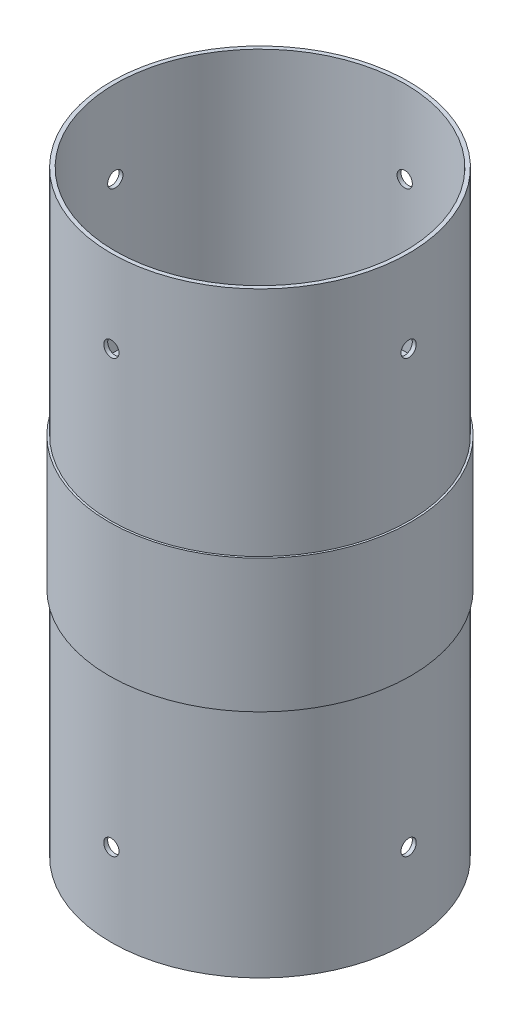
from build123d import *

# Parameters (mm, degrees)
SKETCH1_R                = 38
SKETCH1_R_2              = 37
BOSS_EXTRUDE1_DEPTH      = 152.4
SKETCH2_R                = 38.5
BOSS_EXTRUDE2_DEPTH      = 17
BOSS_EXTRUDE2_DEPTH_BACK = 17
SKETCH3_R                = 1.95
CUT_EXTRUDE1_DEPTH       = 39.5
SKETCH4_R                = 1.95
CUT_EXTRUDE2_DEPTH       = 39.5


with BuildPart() as part:
    # Sketch1 → Boss-Extrude1 (new body)
    with BuildSketch(Plane(origin=(0, 0, 0), x_dir=(1, 0, 0), z_dir=(0, 1, 0))):
        Circle(SKETCH1_R)
        Circle(SKETCH1_R_2, mode=Mode.SUBTRACT)
    extrude(amount=BOSS_EXTRUDE1_DEPTH)

    # Sketch2 → Boss-Extrude2 (add, two sides)
    with BuildSketch(Plane(origin=(0, 76.2, 0), x_dir=(1, 0, 0), z_dir=(0, 1, 0))) as boss_extrude2_sk:
        Circle(SKETCH2_R)
    extrude(amount=BOSS_EXTRUDE2_DEPTH)
    extrude(boss_extrude2_sk.sketch, amount=-BOSS_EXTRUDE2_DEPTH_BACK)

    # Sketch3 → Cut-Extrude1 (cut, symmetric)
    with BuildSketch(Plane(origin=(0, 0, 0), x_dir=(0, 0, -1), z_dir=(1, 0, 0))):
        with Locations((0, 131.3)):
            Circle(SKETCH3_R)
    cut_extrude1 = extrude(amount=CUT_EXTRUDE1_DEPTH, both=True, mode=Mode.SUBTRACT)

    # Sketch4 → Cut-Extrude2 (cut, symmetric)
    with BuildSketch(Plane.XY):
        with Locations((0, 131.3)):
            Circle(SKETCH4_R)
    cut_extrude2 = extrude(amount=CUT_EXTRUDE2_DEPTH, both=True, mode=Mode.SUBTRACT)

    # Mirror1: Cut-Extrude1, Cut-Extrude2 across plane
    add(cut_extrude1.mirror(Plane.ZX.offset(76.2)), mode=Mode.SUBTRACT)
    add(cut_extrude2.mirror(Plane.ZX.offset(76.2)), mode=Mode.SUBTRACT)


solid = part.part
